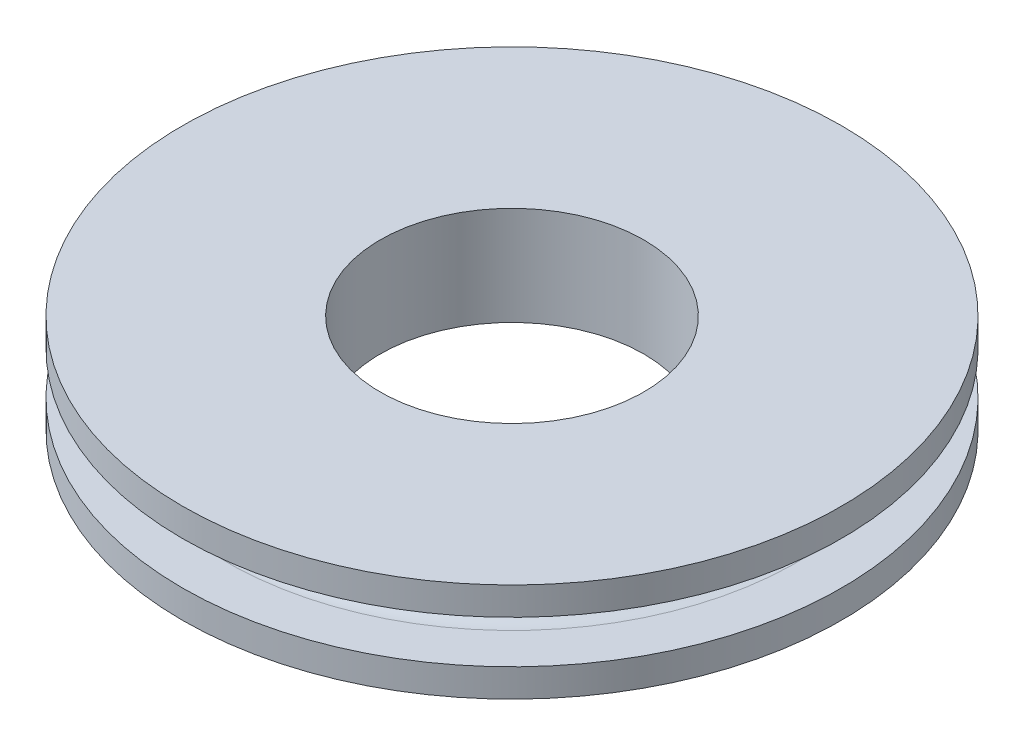
from build123d import *


with BuildPart() as part:
    # Sketch1 → Revolve1 (revolve)
    with BuildSketch(Plane.XY):
        with BuildLine():
            Line((4, 1.5), (4, -1.5))
            Line((4, -1.5), (8.65, -1.5))
            Line((8.65, -1.5), (10, -1.5))
            Line((10, -1.5), (10, -0.65))
            Line((10, -0.65), (8.65, -0.65))
            ThreePointArc((8.65, -0.65), (8, 0), (8.65, 0.65))
            Line((8.65, 0.65), (10, 0.65))
            Line((10, 0.65), (10, 1.5))
            Line((10, 1.5), (8.65, 1.5))
            Line((8.65, 1.5), (4, 1.5))
        make_face()
    revolve(axis=Axis((0, -1.5, 0), (0, 1, 0)))


solid = part.part
